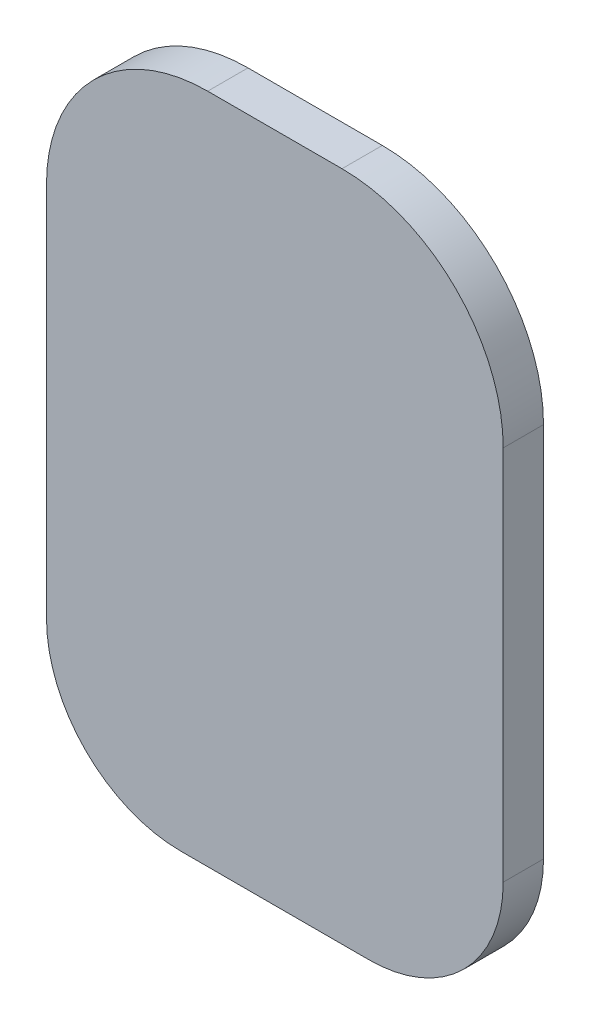
from build123d import *

# Parameters (mm, degrees)
BOSS_EXTRUDE1_DEPTH = 3


with BuildPart() as part:
    # Sketch1 → Boss-Extrude1 (new body)
    with BuildSketch(Plane.XY):
        with BuildLine():
            Line((-5, -21.5), (5, -21.5))
            ThreePointArc((5, -21.5), (13.485281374, -25.014718626), (17, -33.5))
            Line((17, -33.5), (17, -61.5))
            ThreePointArc((17, -61.5), (14.071067812, -68.571067812), (7, -71.5))
            Line((7, -71.5), (0.5, -71.5))
            Line((0.5, -71.5), (-0.5, -71.5))
            Line((-0.5, -71.5), (-7, -71.5))
            ThreePointArc((-7, -71.5), (-14.071067812, -68.571067812), (-17, -61.5))
            Line((-17, -61.5), (-17, -33.5))
            ThreePointArc((-17, -33.5), (-13.485281374, -25.014718626), (-5, -21.5))
        make_face()
    extrude(amount=BOSS_EXTRUDE1_DEPTH)


solid = part.part
